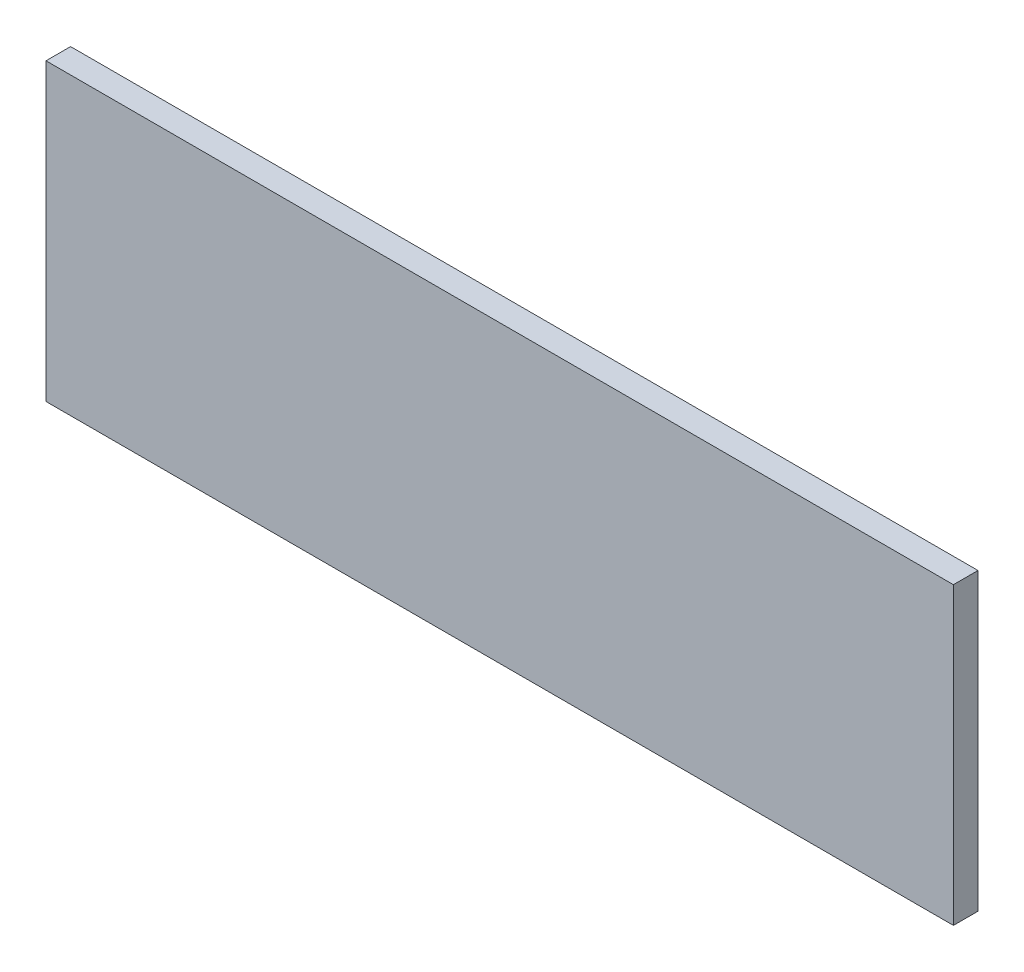
from build123d import *

# Parameters (mm, degrees)
SKETCH1_W           = 46.125
SKETCH1_H           = 15
BOSS_EXTRUDE1_DEPTH = 1.25


with BuildPart() as part:
    # Sketch1 → Boss-Extrude1 (new body)
    with BuildSketch(Plane.XY):
        with Locations((23.0625, 7.5)):
            Rectangle(SKETCH1_W, SKETCH1_H)
    extrude(amount=BOSS_EXTRUDE1_DEPTH)


solid = part.part
